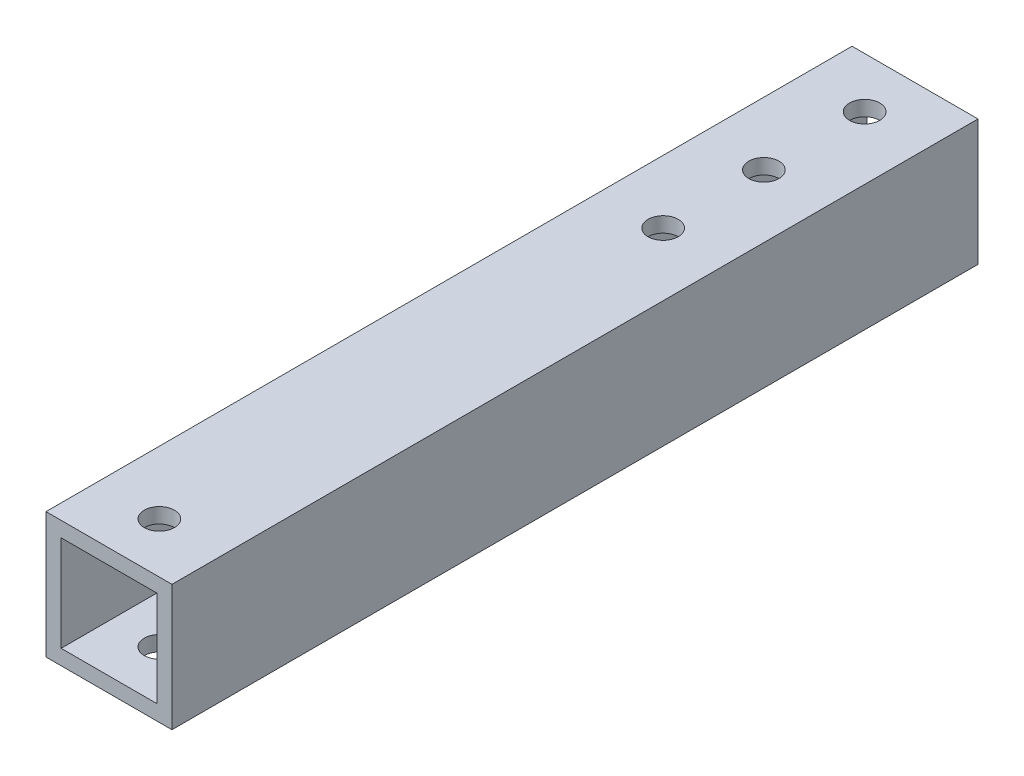
from build123d import *

# Parameters (mm, degrees)
SKETCH1_W           = 25
SKETCH1_H           = 25
SKETCH1_W_2         = 19
SKETCH1_H_2         = 19
BOSS_EXTRUDE1_DEPTH = 160
SKETCH2_R           = 3
CUT_EXTRUDE1_DEPTH  = 26


with BuildPart() as part:
    # Sketch1 → Boss-Extrude1 (new body)
    with BuildSketch(Plane.XY):
        with Locations((12.5, 12.5)):
            Rectangle(SKETCH1_W, SKETCH1_H)
        with Locations((12.5, 12.5)):
            Rectangle(SKETCH1_W_2, SKETCH1_H_2, mode=Mode.SUBTRACT)
    extrude(amount=BOSS_EXTRUDE1_DEPTH)

    # Sketch2 → Cut-Extrude1 (cut, through all)
    with BuildSketch(Plane.XZ):
        with Locations((12.5, 10)):
            Circle(SKETCH2_R)
        with Locations((12.5, 30)):
            Circle(SKETCH2_R)
        with Locations((12.5, 50)):
            Circle(SKETCH2_R)
        with Locations((12.5, 150)):
            Circle(SKETCH2_R)
    extrude(amount=-CUT_EXTRUDE1_DEPTH, mode=Mode.SUBTRACT)


solid = part.part
